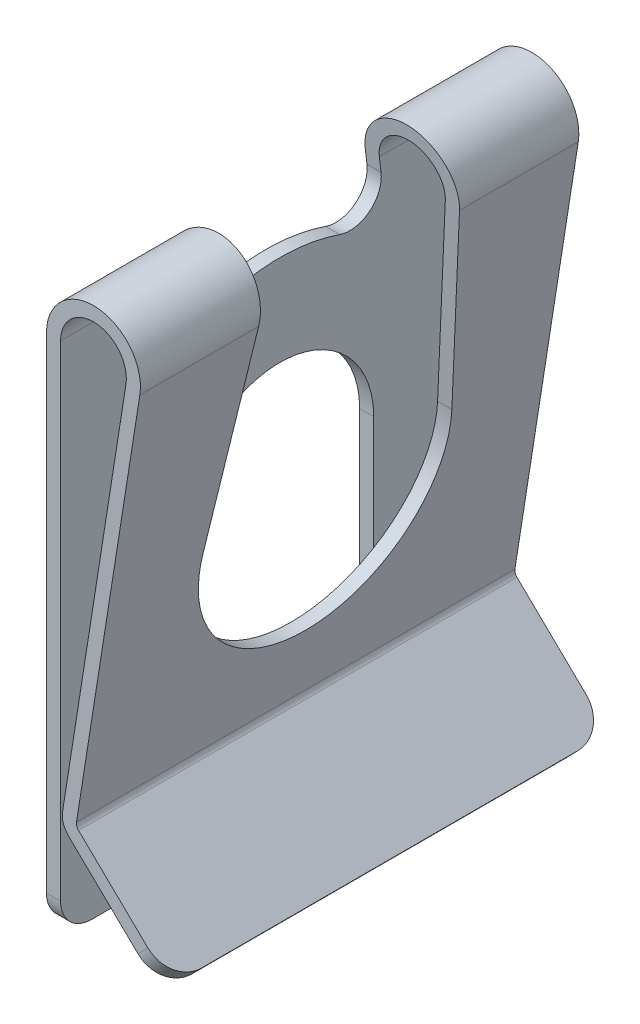
from build123d import *

# Parameters (mm, degrees)
BOSS_EXTRUDE1_DEPTH      = 7
BOSS_EXTRUDE1_DEPTH_BACK = 7
CUT_EXTRUDE1_DEPTH       = 0.45
CUT_EXTRUDE2_DEPTH       = 3.9
CUT_EXTRUDE3_DEPTH       = 3.9
CUT_EXTRUDE4_DEPTH       = 0.45
CUT_EXTRUDE5_DEPTH       = 0.45
CUT_EXTRUDE6_DEPTH       = 0.45
CUT_EXTRUDE7_DEPTH       = 0.45
CUT_EXTRUDE8_DEPTH       = 0.9
CUT_EXTRUDE8_DEPTH_BACK  = 0.9


with BuildPart() as part:
    # Sketch1 → Boss-Extrude1 (new, two sides: drawn at the far end of the back side and taken through both)
    with BuildSketch(Plane.XY.offset(-BOSS_EXTRUDE1_DEPTH_BACK)):
        with BuildLine():
            Line((0, 7.1), (0, -9.4))
            Line((0, -9.4), (0.45, -9.4))
            Line((0.45, -9.4), (0.45, 7.1))
            ThreePointArc((0.45, 7.1), (1.582064395, 8.146788152), (2.537172257, 6.936373264))
            Line((2.537172257, 6.936373264), (0.513952578, -5.888103783))
            ThreePointArc((0.513952578, -5.888103783), (0.540554577, -6.207374008), (0.711367038, -6.478416895))
            Line((0.711367038, -6.478416895), (3.64329211, -9.314940681))
            Line((3.64329211, -9.314940681), (3.956184866, -8.99152435))
            Line((3.956184866, -8.99152435), (1.024259794, -6.155000564))
            ThreePointArc((1.024259794, -6.155000564), (0.967322307, -6.064652935), (0.958454974, -5.958229527))
            Line((0.958454974, -5.958229527), (2.981674653, 6.86624752))
            ThreePointArc((2.981674653, 6.86624752), (1.61723485, 8.595411646), (0, 7.1))
        make_face()
    extrude(amount=BOSS_EXTRUDE1_DEPTH + BOSS_EXTRUDE1_DEPTH_BACK)

    # Sketch2 → Cut-Extrude1 (cut)
    with BuildSketch(Plane(origin=(0, 0, 0), x_dir=(0, 0, -1), z_dir=(1, 0, 0))):
        with BuildLine():
            Line((-3, 0), (-3, -9.4))
            Line((-3, -9.4), (3, -9.4))
            Line((3, -9.4), (3, 0))
            ThreePointArc((3, 0), (0, 3), (-3, 0))
        make_face()
    extrude(amount=CUT_EXTRUDE1_DEPTH, mode=Mode.SUBTRACT)

    # Sketch3 → Cut-Extrude2 (cut)
    with BuildSketch(Plane(origin=(0.45, 0, 0), x_dir=(0, 0, -1), z_dir=(1, 0, 0))):
        with BuildLine():
            Line((3.97169805, 0.474989052), (3, 8.6))
            Line((3, 8.6), (-3, 8.6))
            Line((-3, 8.6), (-3.97169805, 0.474989052))
            ThreePointArc((-3.97169805, 0.474989052), (0, -4), (3.97169805, 0.474989052))
        make_face()
    extrude(amount=CUT_EXTRUDE2_DEPTH, mode=Mode.SUBTRACT)

    # Sketch4 → Cut-Extrude3 (cut)
    with BuildSketch(Plane(origin=(0.45, 0, 0), x_dir=(0, 0, -1), z_dir=(1, 0, 0))):
        with BuildLine():
            Line((3.233838828, 6.644718687), (3, 8.6))
            Line((3, 8.6), (-3, 8.6))
            Line((-3, 8.6), (-3.233838828, 6.644718687))
            ThreePointArc((-3.233838828, 6.644718687), (-2.869340143, 5.748101911), (-1.916144125, 5.580178464))
            ThreePointArc((-1.916144125, 5.580178464), (0, 5.9), (1.916144125, 5.580178464))
            ThreePointArc((1.916144125, 5.580178464), (2.869340143, 5.748101911), (3.233838828, 6.644718687))
        make_face()
    extrude(amount=-CUT_EXTRUDE3_DEPTH, mode=Mode.SUBTRACT)

    # Sketch5 → Cut-Extrude4 (cut)
    with BuildSketch(Plane(origin=(0, 0, 0), x_dir=(0, 0, -1), z_dir=(1, 0, 0))):
        with BuildLine():
            Line((-7, -9.4), (-6, -9.4))
            ThreePointArc((-6, -9.4), (-6.707106781, -9.107106781), (-7, -8.4))
            Line((-7, -8.4), (-7, -9.4))
        make_face()
    extrude(amount=CUT_EXTRUDE4_DEPTH, mode=Mode.SUBTRACT)

    # Sketch6 → Cut-Extrude5 (cut)
    with BuildSketch(Plane(origin=(0, 0, 0), x_dir=(0, 0, -1), z_dir=(1, 0, 0))):
        with BuildLine():
            Line((6, -9.4), (7, -9.4))
            Line((7, -9.4), (7, -8.4))
            ThreePointArc((7, -8.4), (6.707106781, -9.107106781), (6, -9.4))
        make_face()
    extrude(amount=CUT_EXTRUDE5_DEPTH, mode=Mode.SUBTRACT)

    # Sketch7 → Cut-Extrude6 (cut)
    with BuildSketch(Plane(origin=(0, 0, 0), x_dir=(0, 0, -1), z_dir=(1, 0, 0))):
        with BuildLine():
            Line((3, -9.4), (3.5, -9.4))
            ThreePointArc((3.5, -9.4), (3.146446609, -9.253553391), (3, -8.9))
            Line((3, -8.9), (3, -9.4))
        make_face()
    extrude(amount=CUT_EXTRUDE6_DEPTH, mode=Mode.SUBTRACT)

    # Sketch8 → Cut-Extrude7 (cut)
    with BuildSketch(Plane(origin=(0, 0, 0), x_dir=(0, 0, -1), z_dir=(1, 0, 0))):
        with BuildLine():
            Line((-3.5, -9.4), (-3, -9.4))
            Line((-3, -9.4), (-3, -8.9))
            ThreePointArc((-3, -8.9), (-3.146446609, -9.253553391), (-3.5, -9.4))
        make_face()
    extrude(amount=CUT_EXTRUDE7_DEPTH, mode=Mode.SUBTRACT)

    # Sketch9 → Cut-Extrude8 (cut, two sides: drawn at the far end of the back side and taken through both)
    with BuildSketch(Plane(origin=(-2.580622377, -2.667416888, 0), x_dir=(0.718702958168856, -0.6953172354539585, 0), z_dir=(0.6953172354539585, 0.718702958168856, 0)).offset(-CUT_EXTRUDE8_DEPTH_BACK)):
        with BuildLine():
            Line((8.094816521, -7), (8.094816521, -8))
            Line((8.094816521, -8), (10.094816521, -8))
            Line((10.094816521, -8), (10.094816521, 8))
            Line((10.094816521, 8), (8.094816521, 8))
            Line((8.094816521, 8), (8.094816521, 7))
            ThreePointArc((8.094816521, 7), (8.801923302, 6.707106781), (9.094816521, 6))
            Line((9.094816521, 6), (9.094816521, -6))
            ThreePointArc((9.094816521, -6), (8.801923302, -6.707106781), (8.094816521, -7))
        make_face()
    extrude(amount=CUT_EXTRUDE8_DEPTH + CUT_EXTRUDE8_DEPTH_BACK, mode=Mode.SUBTRACT)


solid = part.part
